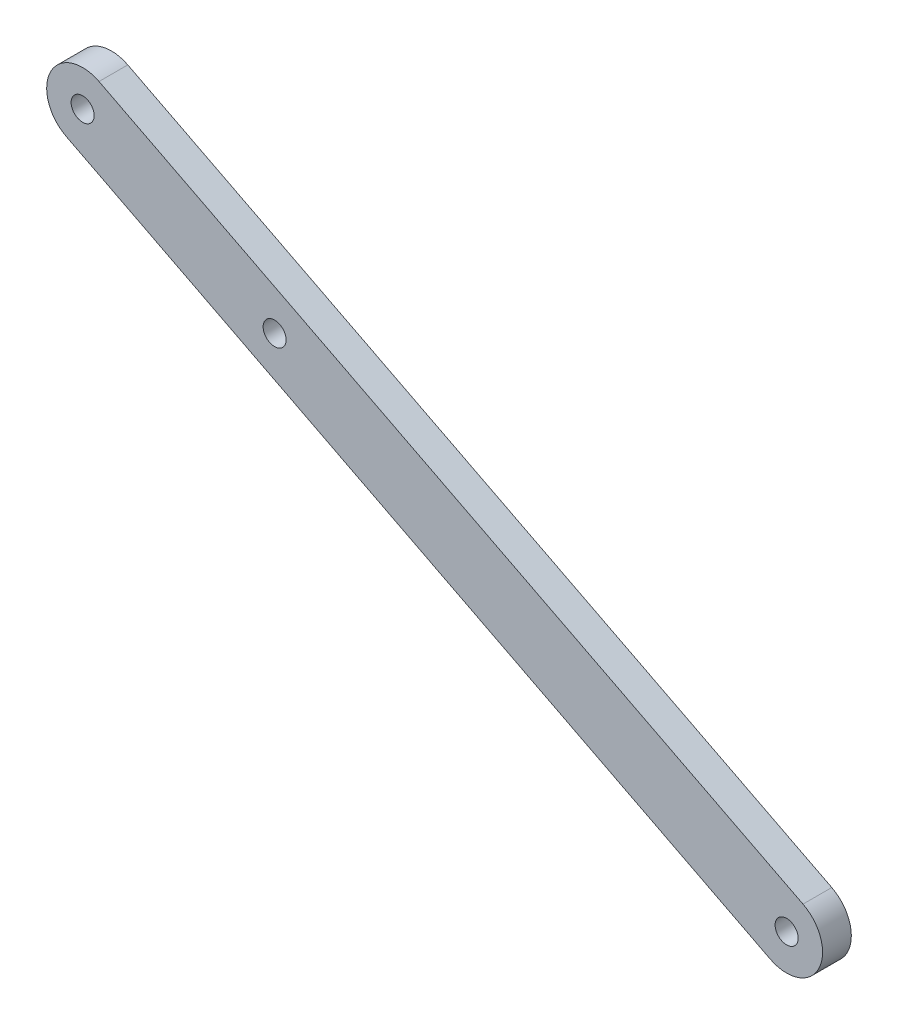
from build123d import *

# Parameters (mm, degrees)
SKETCH1_R           = 1.6
BOSS_EXTRUDE1_DEPTH = 4


with BuildPart() as part:
    # Sketch1 → Boss-Extrude1 (new body)
    with BuildSketch(Plane.XY):
        with BuildLine():
            Line((-2.278461986, -4.450686574), (-100.193566609, 45.675477121))
            ThreePointArc((-100.193566609, 45.675477121), (-102.365791196, 52.404625681), (-95.636642636, 54.576850269))
            Line((-95.636642636, 54.576850269), (2.278461986, 4.450686574))
            ThreePointArc((2.278461986, 4.450686574), (4.450686574, -2.278461986), (-2.278461986, -4.450686574))
        make_face()
        with Locations((-97.915104623, 50.126163695)):
            Circle(SKETCH1_R, mode=Mode.SUBTRACT)
        Circle(SKETCH1_R, mode=Mode.SUBTRACT)
        with Locations((-71.21098518, 36.455391778)):
            Circle(SKETCH1_R, mode=Mode.SUBTRACT)
    extrude(amount=BOSS_EXTRUDE1_DEPTH)


solid = part.part
